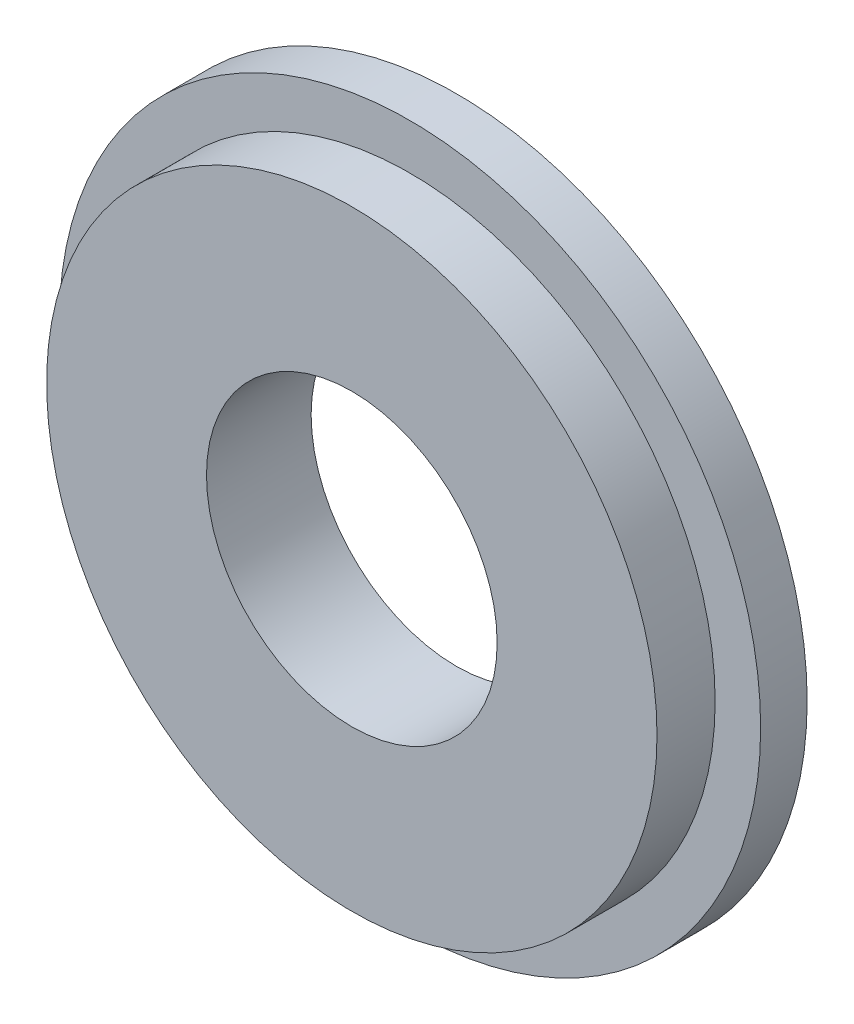
from build123d import *

# Parameters (mm, degrees)
SKETCH2_R             = 30.165
SKETCH2_R_2           = 12.5
BOSS_EXTRUDE1_DEPTH   = 4
SKETCH3_R             = 26.25
SKETCH3_R_2           = 12.5
BOSS_EXTRUDE2_DEPTH   = 5
CROQUIS1_R            = 1.5
CROQUIS1_R_2          = 1.636681132
CORTAR_EXTRUIR1_DEPTH = 5


with BuildPart() as part:
    # Sketch2 → Boss-Extrude1 (new body)
    with BuildSketch(Plane.XY):
        Circle(SKETCH2_R)
        Circle(SKETCH2_R_2, mode=Mode.SUBTRACT)
    extrude(amount=BOSS_EXTRUDE1_DEPTH)

    # Sketch3 → Boss-Extrude2 (add)
    with BuildSketch(Plane.XY.offset(4)):
        Circle(SKETCH3_R)
        Circle(SKETCH3_R_2, mode=Mode.SUBTRACT)
    extrude(amount=BOSS_EXTRUDE2_DEPTH)

    # Croquis1 → Cortar-Extruir1 (cut)
    with BuildSketch(Plane(origin=(0, 0, 0), x_dir=(-1, 0, 0), z_dir=(0, 0, -1))):
        with Locations((0, 20)):
            Circle(CROQUIS1_R)
        with Locations((0, -20)):
            Circle(CROQUIS1_R_2)
        with Locations((20, 0)):
            Circle(CROQUIS1_R)
        with Locations((-20, 0)):
            Circle(CROQUIS1_R)
    extrude(amount=-CORTAR_EXTRUIR1_DEPTH, mode=Mode.SUBTRACT)


solid = part.part
